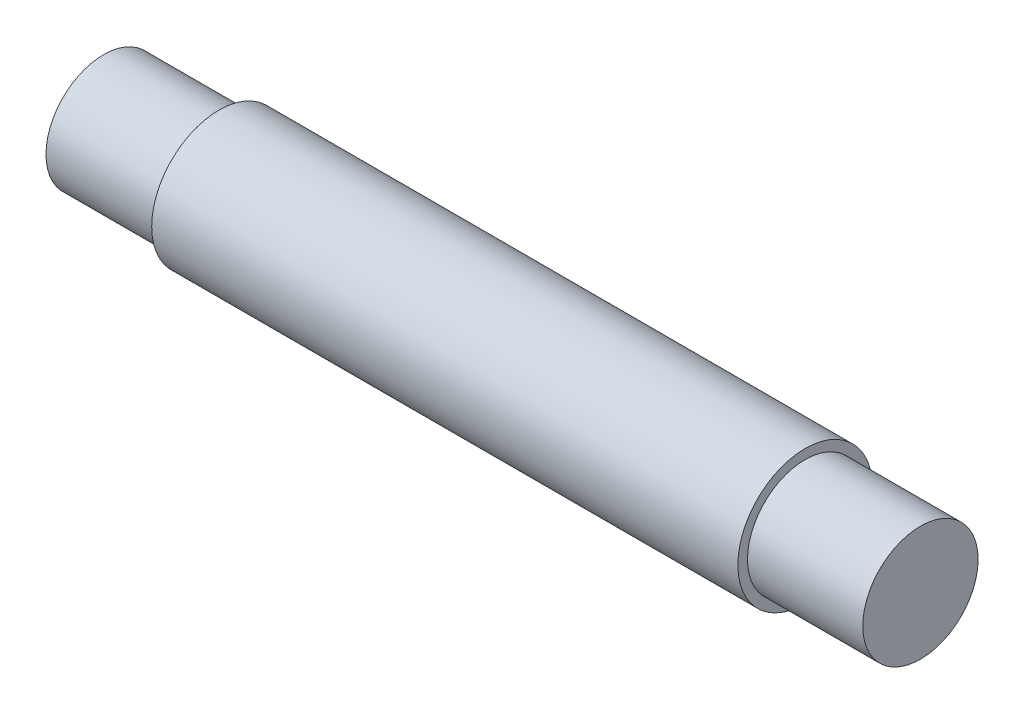
from build123d import *

# Parameters (mm, degrees)
SKETCH_1_R          = 7
EXTRUDE_1_DEPTH     = 85
SKETCH_2_R          = 7.5
SKETCH_2_R_2        = 6
CUT_EXTRUDE_1_DEPTH = 12


with BuildPart() as part:
    # 草图1 → 凸台-拉伸1 (new body)
    with BuildSketch(Plane(origin=(0, 0, 0), x_dir=(0, 0, -1), z_dir=(1, 0, 0))):
        Circle(SKETCH_1_R)
    extrude(amount=EXTRUDE_1_DEPTH)

    # 草图2 → 切除-拉伸1 (cut)
    with BuildSketch(Plane.ZY):
        Circle(SKETCH_2_R)
        Circle(SKETCH_2_R_2, mode=Mode.SUBTRACT)
    cut_extrude_1 = extrude(amount=-CUT_EXTRUDE_1_DEPTH, mode=Mode.SUBTRACT)

    # 镜向1: 切除-拉伸1 across plane
    add(cut_extrude_1.mirror(Plane(origin=(42.5, 0, 0), x_dir=(0, 0, 1), z_dir=(1, 0, 0))), mode=Mode.SUBTRACT)


solid = part.part
